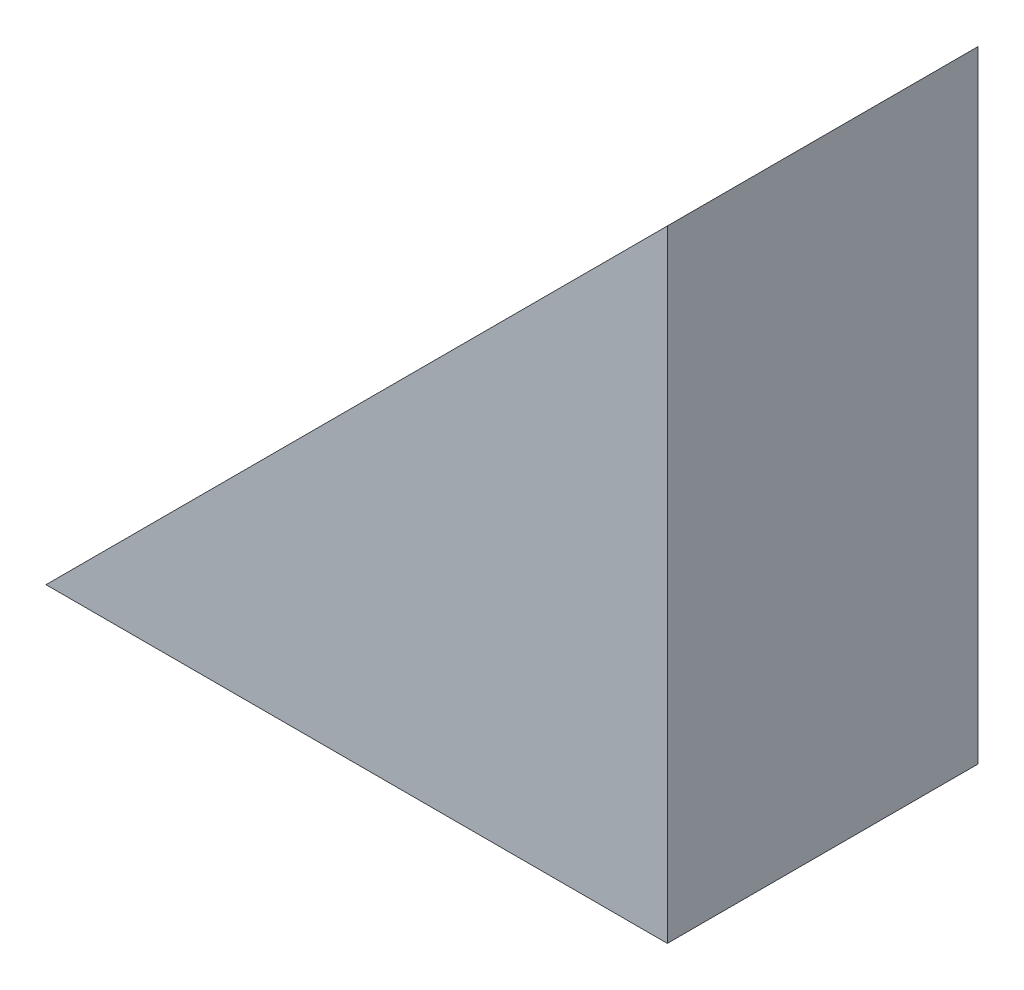
from build123d import *

# Parameters (mm, degrees)
BOSS_EXTRUDE1_DEPTH = 10


with BuildPart() as part:
    # Sketch1 → Boss-Extrude1 (new body)
    with BuildSketch(Plane.XY):
        Polygon((0, 0), (0, 20), (-20, 0), align=None)
    extrude(amount=BOSS_EXTRUDE1_DEPTH)


solid = part.part
